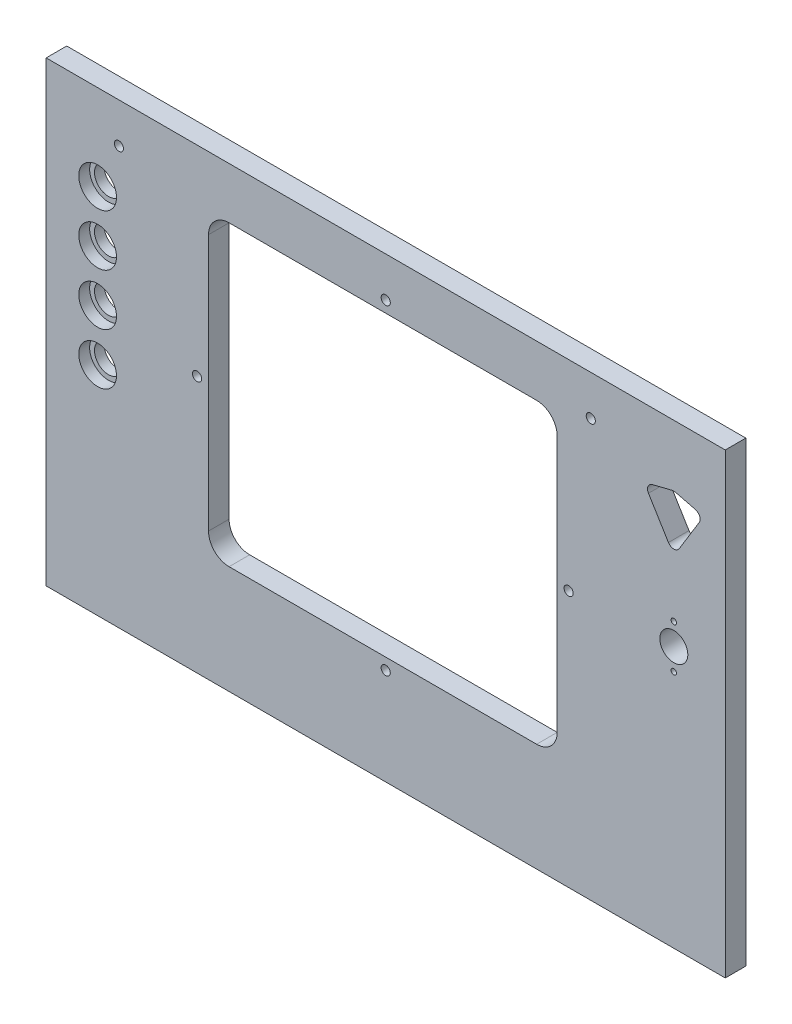
from build123d import *

# Parameters (mm, degrees)
SKETCH1_W           = 594
SKETCH1_H           = 400
SKETCH1_R           = 12.25
BOSS_EXTRUDE1_DEPTH = 18
SKETCH2_R           = 16.5
CUT_EXTRUDE1_DEPTH  = 9.525
SKETCH3_R           = 4
CUT_EXTRUDE2_DEPTH  = 80
SKETCH4_R           = 2.38125
CUT_EXTRUDE3_DEPTH  = 9.525


with BuildPart() as part:
    # Sketch1 → Boss-Extrude1 (new body)
    with BuildSketch(Plane.XY):
        Rectangle(SKETCH1_W, SKETCH1_H)
        with Locations((252, 28.55)):
            Circle(SKETCH1_R, mode=Mode.SUBTRACT)
        with Locations((-252, 125)):
            Circle(SKETCH1_R, mode=Mode.SUBTRACT)
        with Locations((-252, 80)):
            Circle(SKETCH1_R, mode=Mode.SUBTRACT)
        with Locations((-252, 35)):
            Circle(SKETCH1_R, mode=Mode.SUBTRACT)
        with Locations((-252, -10)):
            Circle(SKETCH1_R, mode=Mode.SUBTRACT)
        with BuildLine():
            Line((-137, -105.42), (132, -105.42))
            ThreePointArc((132, -105.42), (144.727922061, -100.147922061), (150, -87.42))
            Line((150, -87.42), (150, 137.08))
            ThreePointArc((150, 137.08), (144.727922061, 149.807922061), (132, 155.08))
            Line((132, 155.08), (-137, 155.08))
            ThreePointArc((-137, 155.08), (-149.727922061, 149.807922061), (-155, 137.08))
            Line((-155, 137.08), (-155, -87.42))
            ThreePointArc((-155, -87.42), (-149.727922061, -100.147922061), (-137, -105.42))
        make_face(mode=Mode.SUBTRACT)
        with BuildLine():
            Line((254.386023622, 145.979320454), (270.808070866, 141.845754885))
            ThreePointArc((270.808070866, 141.845754885), (274.565595901, 138.584722637), (274.166216108, 133.625506823))
            Line((274.166216108, 133.625506823), (256.703716108, 105.050506823))
            ThreePointArc((256.703716108, 105.050506823), (252, 102.4125), (247.296283892, 105.050506823))
            Line((247.296283892, 105.050506823), (229.833783892, 133.625506823))
            ThreePointArc((229.833783892, 133.625506823), (229.434404099, 138.584722637), (233.191929134, 141.845754885))
            Line((233.191929134, 141.845754885), (249.613976378, 145.979320454))
            ThreePointArc((249.613976378, 145.979320454), (252, 146.275), (254.386023622, 145.979320454))
        make_face(mode=Mode.SUBTRACT)
    extrude(amount=BOSS_EXTRUDE1_DEPTH)

    # Sketch2 → Cut-Extrude1 (cut)
    with BuildSketch(Plane.XY.offset(18)):
        with Locations((-252, 125)):
            Circle(SKETCH2_R)
        with Locations((-252, 80)):
            Circle(SKETCH2_R)
        with Locations((-252, 35)):
            Circle(SKETCH2_R)
        with Locations((-252, -10)):
            Circle(SKETCH2_R)
    extrude(amount=-CUT_EXTRUDE1_DEPTH, mode=Mode.SUBTRACT)

    # Sketch3 → Cut-Extrude2 (cut)
    with BuildSketch(Plane.XY.offset(18)):
        with Locations((0, 165.075)):
            Circle(SKETCH3_R)
        with Locations((-233.3625, 165.075)):
            Circle(SKETCH3_R)
        with Locations((179.3875, 165.075)):
            Circle(SKETCH3_R)
        with Locations((0, -115.42)):
            Circle(SKETCH3_R)
        with Locations((-165, 24.83)):
            Circle(SKETCH3_R)
        with Locations((160, 24.83)):
            Circle(SKETCH3_R)
    extrude(amount=-CUT_EXTRUDE2_DEPTH, mode=Mode.SUBTRACT)

    # Sketch4 → Cut-Extrude3 (cut)
    with BuildSketch(Plane.XY.offset(18)):
        with Locations((252, 47.6)):
            Circle(SKETCH4_R)
        with Locations((252, 9.5)):
            Circle(SKETCH4_R)
    extrude(amount=-CUT_EXTRUDE3_DEPTH, mode=Mode.SUBTRACT)


solid = part.part
